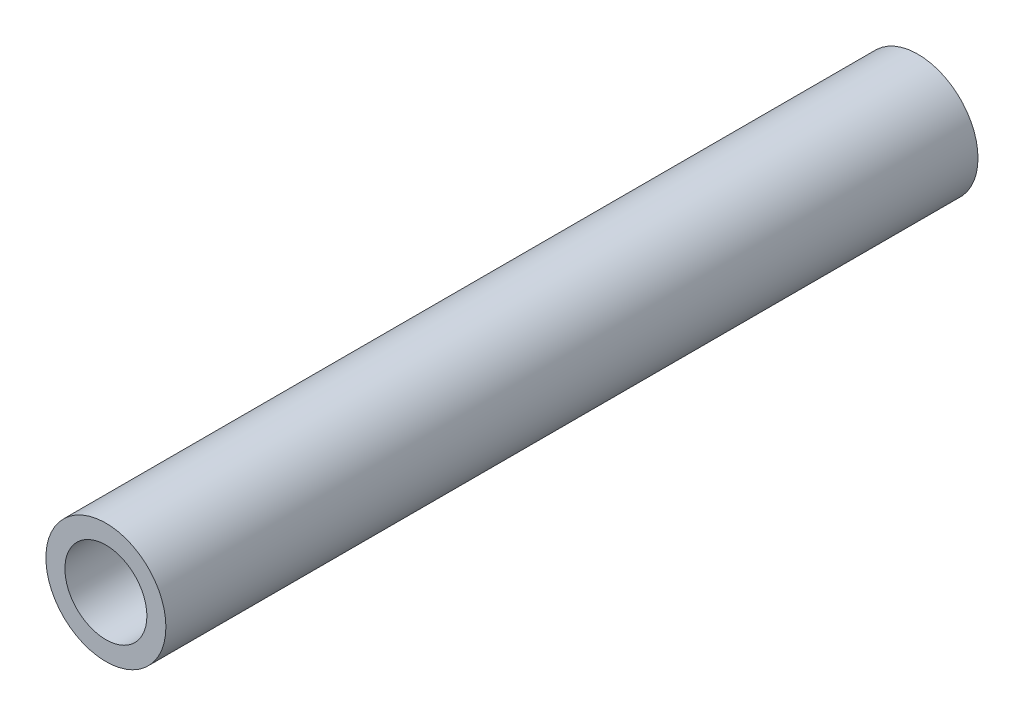
from build123d import *

# Parameters (mm, degrees)
ESQUISSE1_R        = 6
ESQUISSE1_R_2      = 4.1
BOSS_EXTRU_1_DEPTH = 81.2


with BuildPart() as part:
    # Esquisse1 → Boss.-Extru.1 (new body)
    with BuildSketch(Plane.XY):
        Circle(ESQUISSE1_R)
        Circle(ESQUISSE1_R_2, mode=Mode.SUBTRACT)
    extrude(amount=BOSS_EXTRU_1_DEPTH)


solid = part.part
